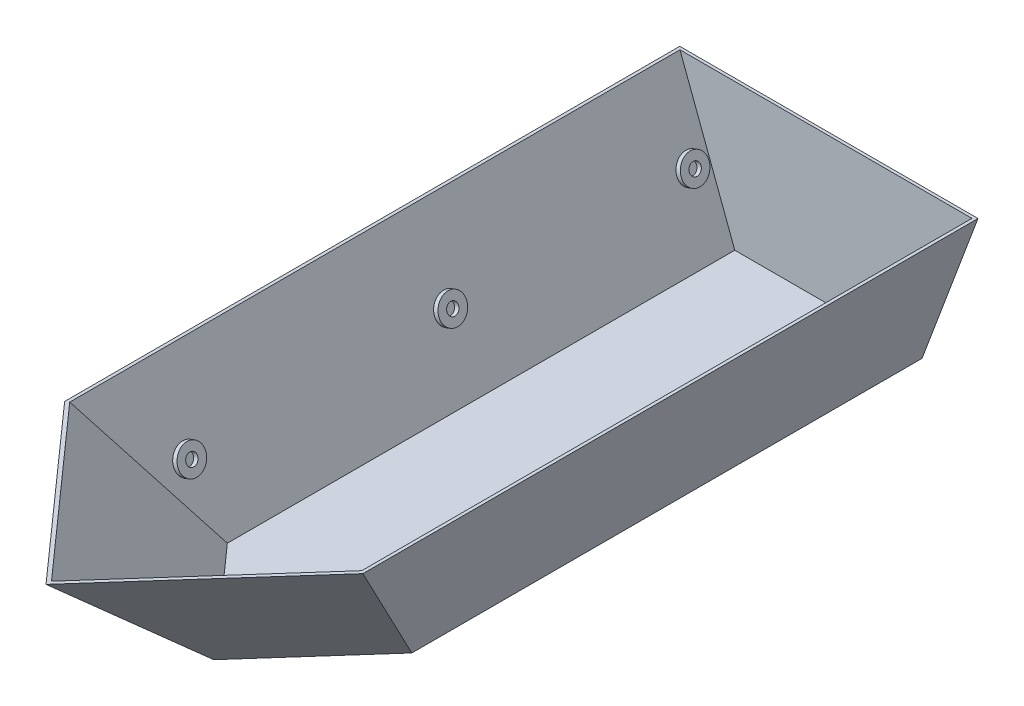
from build123d import *

# Parameters (mm, degrees)
BOSS_EXTRUDE1_DEPTH = 2133.6
CUT_EXTRUDE2_DEPTH  = 613.218203925
SHELL1_T            = -7.9375
SKETCH14_R          = 38.1
SKETCH14_R_2        = 15.875
BOSS_EXTRUDE2_DEPTH = 12.7


with BuildPart() as part:
    # Sketch1 → Boss-Extrude1 (new body)
    with BuildSketch(Plane.XY):
        Polygon((0, 0), (508, 0), (660.4, 406.4), (-152.4, 406.4), align=None)
    extrude(amount=BOSS_EXTRUDE1_DEPTH)

    # Sketch13 → Cut-Extrude2 (cut, symmetric, along a direction that is not the sketch's normal)
    with BuildSketch(Plane(origin=(254, 0, 0), x_dir=(0, 0, -1), z_dir=(1, 0, 0))):
        Polygon((-2133.6, 0), (-3174.648587482, 0), (-3174.648587482, 406.4), (-2133.6, 406.4), (-1676.4, 0), align=None)
    cut_extrude2 = extrude(amount=CUT_EXTRUDE2_DEPTH, dir=(0.664363839, 0, 0.747409319), both=True, mode=Mode.SUBTRACT)

    # Mirror1: Cut-Extrude2 across plane
    add(cut_extrude2.mirror(Plane(origin=(254, 0, 0), x_dir=(0, 0, 1), z_dir=(1, 0, 0))), mode=Mode.SUBTRACT)

    # Shell1
    shell1_openings = [part.faces().sort_by_distance(p)[0] for p in [
        (254, 406.4, 1097.28),
    ]]
    offset(amount=SHELL1_T, openings=shell1_openings, kind=Kind.INTERSECTION)

    # Sketch14 → Boss-Extrude2 (add)
    with BuildSketch(Plane(origin=(437.937750167, -164.226656313, 0), x_dir=(0, 0, 1), z_dir=(-0.936329178, 0.351123442, 0))):
        with Locations((58.7375, 380.829536089)):
            Circle(SKETCH14_R)
        with Locations((58.7375, 380.829536089)):
            Circle(SKETCH14_R_2, mode=Mode.SUBTRACT)
        with Locations((719.1375, 380.829536089)):
            Circle(SKETCH14_R)
        with Locations((719.1375, 380.829536089)):
            Circle(SKETCH14_R_2, mode=Mode.SUBTRACT)
        with Locations((1430.3375, 380.829536089)):
            Circle(SKETCH14_R)
        with Locations((1430.3375, 380.829536089)):
            Circle(SKETCH14_R_2, mode=Mode.SUBTRACT)
    boss_extrude2 = extrude(amount=BOSS_EXTRUDE2_DEPTH)

    # Mirror2: Boss-Extrude2 across plane
    add(boss_extrude2.mirror(Plane(origin=(254, 0, 0), x_dir=(0, 0, 1), z_dir=(1, 0, 0))))


solid = part.part
